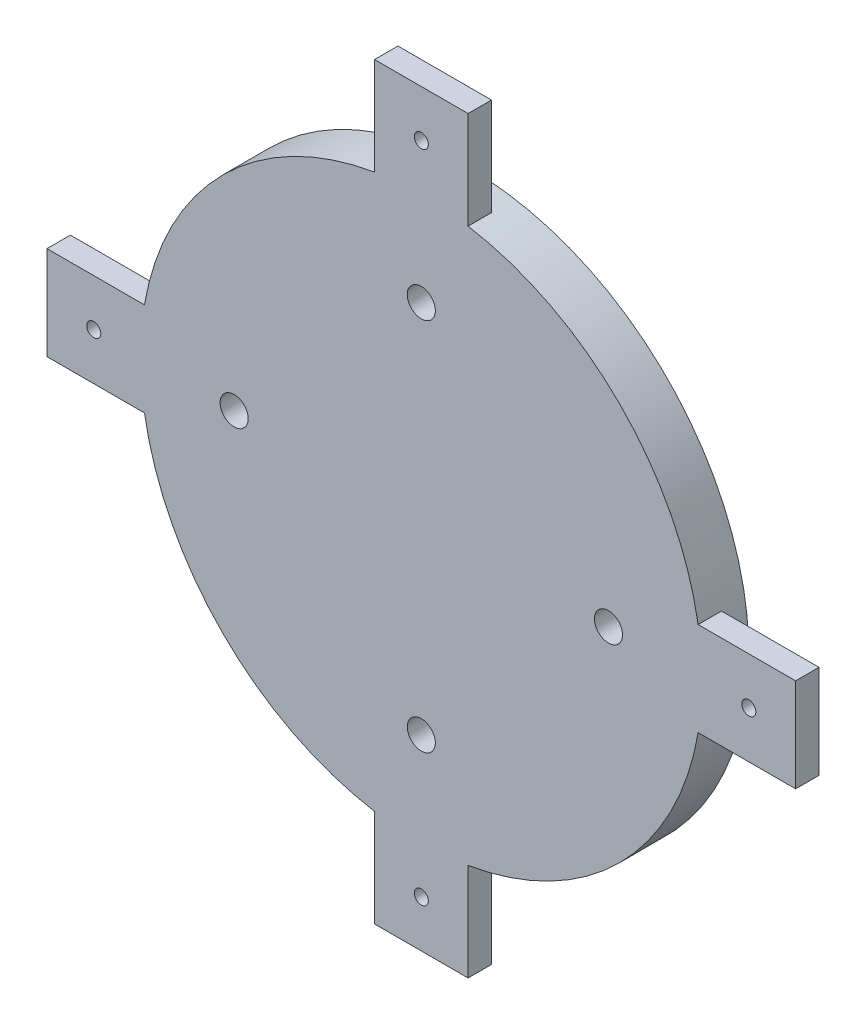
from build123d import *

# Parameters (mm, degrees)
SKETCH1_R           = 60
BOSS_EXTRUDE1_DEPTH = 5
SKETCH3_W           = 20
SKETCH3_H           = 30
SKETCH3_W_2         = 30
SKETCH3_H_2         = 20
BOSS_EXTRUDE2_DEPTH = 5
SKETCH6_R           = 60
BOSS_EXTRUDE3_DEPTH = 10
SKETCH7_R           = 70
CUT_EXTRUDE2_DEPTH  = 5
SKETCH8_R           = 3
CUT_EXTRUDE7_DEPTH  = 5
SKETCH13_R          = 1.5
CUT_EXTRUDE10_DEPTH = 10


with BuildPart() as part:
    # Sketch1 → Boss-Extrude1 (new body)
    with BuildSketch(Plane.XY):
        Circle(SKETCH1_R)
    extrude(amount=BOSS_EXTRUDE1_DEPTH)

    # Sketch3 → Boss-Extrude2 (add)
    with BuildSketch(Plane(origin=(0, 0, 0), x_dir=(-1, 0, 0), z_dir=(0, 0, -1))):
        with Locations((0, -65)):
            Rectangle(SKETCH3_W, SKETCH3_H)
        with Locations((0, 65)):
            Rectangle(SKETCH3_W, SKETCH3_H)
        with Locations((65, 0)):
            Rectangle(SKETCH3_W_2, SKETCH3_H_2)
        with Locations((-65, 0)):
            Rectangle(SKETCH3_W_2, SKETCH3_H_2)
    extrude(amount=BOSS_EXTRUDE2_DEPTH)

    # Sketch6 → Boss-Extrude3 (add)
    with BuildSketch(Plane(origin=(0, 0, 0), x_dir=(-1, 0, 0), z_dir=(0, 0, -1))):
        Circle(SKETCH6_R)
    extrude(amount=BOSS_EXTRUDE3_DEPTH)

    # Sketch7 → Cut-Extrude2 (cut)
    with BuildSketch(Plane.XY.offset(5)):
        Circle(SKETCH7_R)
    extrude(amount=-CUT_EXTRUDE2_DEPTH, mode=Mode.SUBTRACT)

    # Sketch8 → Cut-Extrude7 (cut)
    with BuildSketch(Plane.XY):
        with Locations((0, -40)):
            Circle(SKETCH8_R)
        with Locations((0, 40)):
            Circle(SKETCH8_R)
        with Locations((-40, 0)):
            Circle(SKETCH8_R)
        with Locations((40, 0)):
            Circle(SKETCH8_R)
    extrude(amount=-CUT_EXTRUDE7_DEPTH, mode=Mode.SUBTRACT)

    # Sketch13 → Cut-Extrude10 (cut)
    with BuildSketch(Plane.XY):
        with Locations((-40, 0)):
            Circle(SKETCH13_R)
        with Locations((40, 0)):
            Circle(SKETCH13_R)
        with Locations((-70, 0)):
            Circle(SKETCH13_R)
        with Locations((70, 0)):
            Circle(SKETCH13_R)
        with Locations((0, -40)):
            Circle(SKETCH13_R)
        with Locations((0, -70)):
            Circle(SKETCH13_R)
        with Locations((0, 40)):
            Circle(SKETCH13_R)
        with Locations((0, 70)):
            Circle(SKETCH13_R)
    extrude(amount=-CUT_EXTRUDE10_DEPTH, mode=Mode.SUBTRACT)


solid = part.part
